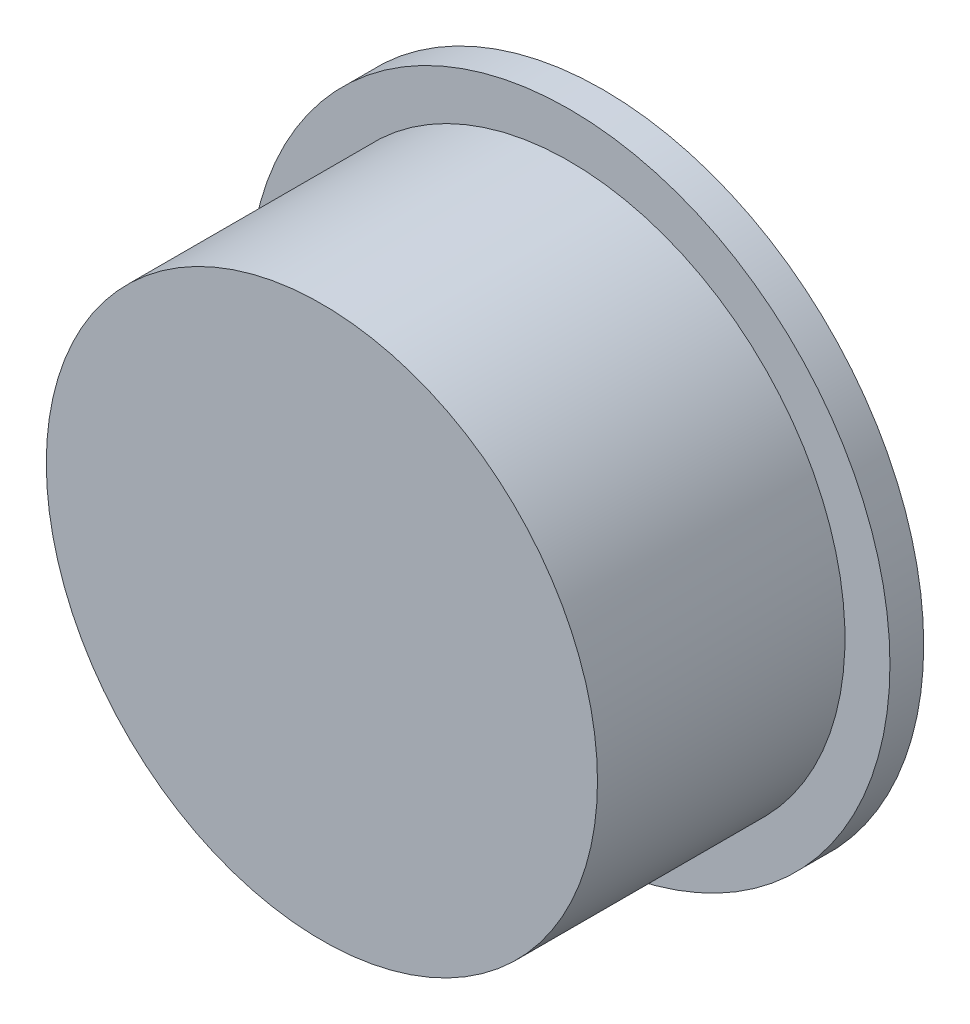
from build123d import *

# Parameters (mm, degrees)
SKETCH1_R                = 24.5
SKETCH1_R_2              = 22.5
BOSS_EXTRUDE1_DEPTH      = 10
BOSS_EXTRUDE1_DEPTH_BACK = 15
SKETCH2_R                = 22.735866394
BOSS_EXTRUDE2_DEPTH      = 2
BOSS_EXTRUDE3_DEPTH      = 2
SKETCH4_R                = 28.5
SKETCH4_R_2              = 24.5
BOSS_EXTRUDE4_DEPTH      = 3


with BuildPart() as part:
    # Sketch1 → Boss-Extrude1 (new body, two sides)
    with BuildSketch(Plane.XY) as boss_extrude1_sk:
        with Locations((-8.522732981, 9.177701176)):
            Circle(SKETCH1_R)
        with Locations((-8.522732981, 9.177701176)):
            Circle(SKETCH1_R_2, mode=Mode.SUBTRACT)
    extrude(amount=BOSS_EXTRUDE1_DEPTH)
    extrude(boss_extrude1_sk.sketch, amount=-BOSS_EXTRUDE1_DEPTH_BACK)

    # Sketch2 → Boss-Extrude2 (add)
    with BuildSketch(Plane.XY.offset(10)):
        with Locations((-8.522732981, 9.177701176)):
            Circle(SKETCH2_R)
    extrude(amount=-BOSS_EXTRUDE2_DEPTH)

    # Sketch3 → Boss-Extrude3 (add)
    with BuildSketch(Plane(origin=(0, 0, -15), x_dir=(-1, 0, 0), z_dir=(0, 0, -1))):
        with BuildLine():
            Line((30.460143949, 14.177701176), (17.182987019, 14.177701176))
            ThreePointArc((17.182987019, 14.177701176), (18.181991244, 11.765891627), (18.522732981, 9.177701176))
            ThreePointArc((18.522732981, 9.177701176), (18.181991244, 6.589510725), (17.182987019, 4.177701176))
            Line((17.182987019, 4.177701176), (30.460143949, 4.177701176))
            ThreePointArc((30.460143949, 4.177701176), (30.881643361, 6.661925629), (31.022732981, 9.177701176))
            ThreePointArc((31.022732981, 9.177701176), (30.881643361, 11.693476723), (30.460143949, 14.177701176))
        make_face()
        with BuildLine():
            Line((17.182987019, 14.177701176), (16.522732981, 14.177701176))
            Line((16.522732981, 14.177701176), (16.522732981, 4.177701176))
            Line((16.522732981, 4.177701176), (17.182987019, 4.177701176))
            ThreePointArc((17.182987019, 4.177701176), (18.181991244, 6.589510725), (18.522732981, 9.177701176))
            ThreePointArc((18.522732981, 9.177701176), (18.181991244, 11.765891627), (17.182987019, 14.177701176))
        make_face()
        with BuildLine():
            Line((16.522732981, 4.177701176), (16.522732981, 14.177701176))
            Line((16.522732981, 14.177701176), (17.182987019, 14.177701176))
            ThreePointArc((17.182987019, 14.177701176), (8.522732981, 19.177701176), (-0.137521057, 14.177701176))
            Line((-0.137521057, 14.177701176), (0.522732981, 14.177701176))
            Line((0.522732981, 14.177701176), (0.522732981, 4.177701176))
            Line((0.522732981, 4.177701176), (-0.137521057, 4.177701176))
            ThreePointArc((-0.137521057, 4.177701176), (8.522732981, -0.822298824), (17.182987019, 4.177701176))
            Line((17.182987019, 4.177701176), (16.522732981, 4.177701176))
        make_face()
        with BuildLine():
            Line((0.522732981, 14.177701176), (-0.137521057, 14.177701176))
            ThreePointArc((-0.137521057, 14.177701176), (-1.477267019, 9.177701176), (-0.137521057, 4.177701176))
            Line((-0.137521057, 4.177701176), (0.522732981, 4.177701176))
            Line((0.522732981, 4.177701176), (0.522732981, 14.177701176))
        make_face()
        with BuildLine():
            ThreePointArc((-0.137521057, 4.177701176), (-1.477267019, 9.177701176), (-0.137521057, 14.177701176))
            Line((-0.137521057, 14.177701176), (-13.414677988, 14.177701176))
            ThreePointArc((-13.414677988, 14.177701176), (-13.836177399, 11.693476723), (-13.977267019, 9.177701176))
            ThreePointArc((-13.977267019, 9.177701176), (-13.836177399, 6.661925629), (-13.414677988, 4.177701176))
            Line((-13.414677988, 4.177701176), (-0.137521057, 4.177701176))
        make_face()
    extrude(amount=-BOSS_EXTRUDE3_DEPTH)

    # Sketch4 → Boss-Extrude4 (add)
    with BuildSketch(Plane(origin=(0, 0, -15), x_dir=(-1, 0, 0), z_dir=(0, 0, -1))):
        with Locations((8.522732981, 9.177701176)):
            Circle(SKETCH4_R)
        with Locations((8.522732981, 9.177701176)):
            Circle(SKETCH4_R_2, mode=Mode.SUBTRACT)
    extrude(amount=-BOSS_EXTRUDE4_DEPTH)


solid = part.part
